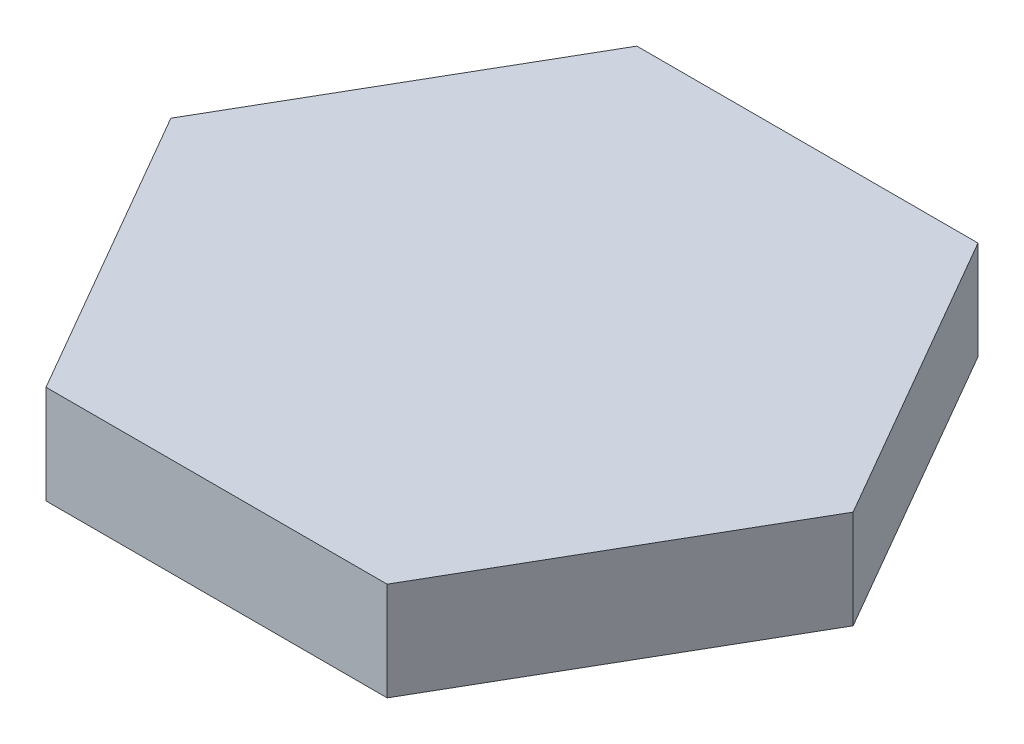
from build123d import *

# Parameters (mm, degrees)
BOSS_EXTRUDE1_DEPTH = 3


with BuildPart() as part:
    # Sketch1 → Boss-Extrude1 (new body)
    with BuildSketch(Plane(origin=(0, 0, 0), x_dir=(1, 0, 0), z_dir=(0, 1, 0))):
        Polygon((5.196152423, 9), (-5.196152423, 9), (-10.392304845, 0), (-5.196152423, -9), (5.196152423, -9), (10.392304845, 0), align=None)
    extrude(amount=BOSS_EXTRUDE1_DEPTH)


solid = part.part
